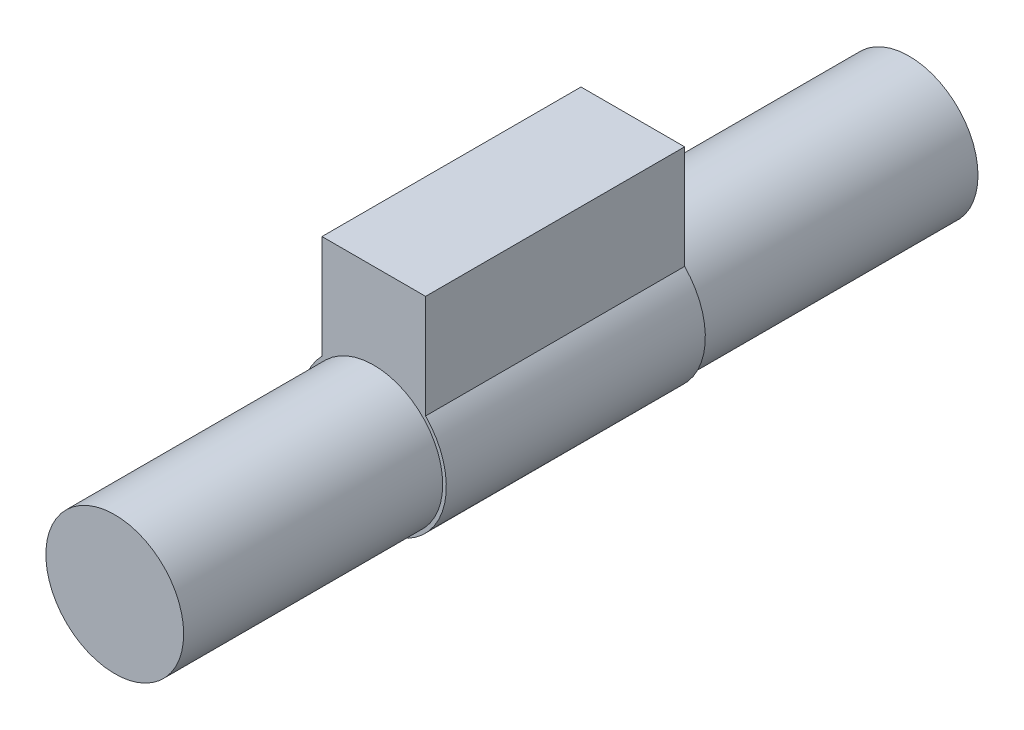
from build123d import *

# Parameters (mm, degrees)
SKETCH1_R           = 3.99
BOSS_EXTRUDE1_DEPTH = 16
BOSS_EXTRUDE7_DEPTH = 15
SKETCH7_R           = 3.99
BOSS_EXTRUDE8_DEPTH = 15


with BuildPart() as part:
    # Sketch1 → Boss-Extrude1 (new body)
    with BuildSketch(Plane.XY):
        with Locations((-14.383915809, -0.854852817)):
            Circle(SKETCH1_R)
    extrude(amount=BOSS_EXTRUDE1_DEPTH)

    # Sketch6 → Boss-Extrude7 (add)
    with BuildSketch(Plane.XY.offset(16)):
        with BuildLine():
            Line((-17.383915809, 2.084534875), (-17.383915809, 8.084534875))
            Line((-17.383915809, 8.084534875), (-11.383915809, 8.084534875))
            Line((-11.383915809, 8.084534875), (-11.383915809, 2.084534875))
            ThreePointArc((-11.383915809, 2.084534875), (-14.383915809, -5.054852817), (-17.383915809, 2.084534875))
        make_face()
    extrude(amount=BOSS_EXTRUDE7_DEPTH)

    # Sketch7 → Boss-Extrude8 (add)
    with BuildSketch(Plane.XY.offset(31)):
        with Locations((-14.383915809, -0.854852817)):
            Circle(SKETCH7_R)
    extrude(amount=BOSS_EXTRUDE8_DEPTH)


solid = part.part
